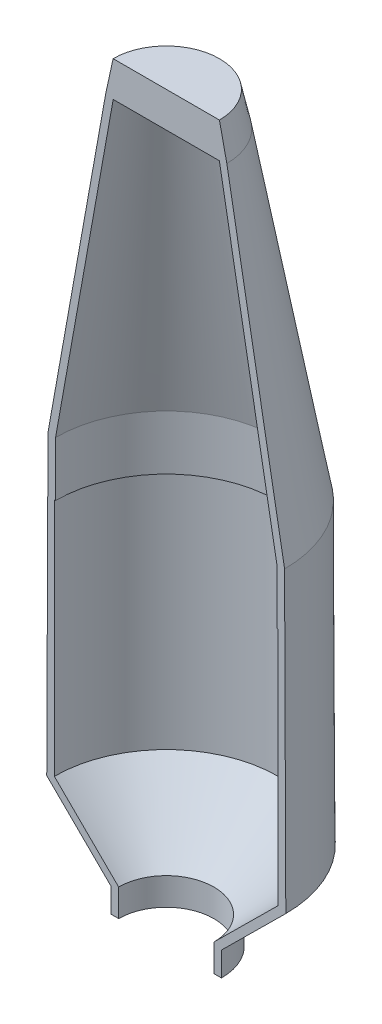
from build123d import *

# Parameters (mm, degrees)
EXTRUDE1_DEPTH = 2540


with BuildPart() as part:
    # Sketch1 → Revolve1 (revolve)
    with BuildSketch(Plane(origin=(0, 0, 0), x_dir=(0, 0, -1), z_dir=(1, 0, 0))):
        with BuildLine():
            Line((889, 5386.324), (1854.2, 0.000254))
            Line((1854.2, 0.000254), (1854.2, -914.399746))
            Line((1854.2, -914.399746), (1875.028, -914.399746))
            Line((1875.028, -914.399746), (1875.028, -4925.059746))
            Line((1875.028, -4925.059746), (797.687, -5991.859746))
            Line((797.687, -5991.859746), (797.687, -6450.585559605))
            Line((797.687, -6450.585559605), (924.687, -6450.585559605))
            Line((924.687, -6450.585559605), (924.687, -6044.830978169))
            Line((924.687, -6044.830978169), (2002.028, -4978.030978169))
            Line((2002.028, -4978.030978169), (1981.2, 11.289201635))
            Line((1981.2, 11.289201635), (1014.008798645, 5408.724898673))
            Line((1014.008798645, 5408.724898673), (797.687, 6403.505182835))
            ThreePointArc((797.687, 6403.505182835), (486.180167613, 6776.837110866), (0, 6783.324))
            Line((0, 6783.324), (0, 5386.324))
            Line((0, 5386.324), (889, 5386.324))
        make_face()
    revolve(axis=Axis((0, 0, 0), (0, 1, 0)))

    # Sketch4 → Extrude1 (cut, symmetric)
    with BuildSketch(Plane(origin=(0, 0, 0), x_dir=(0, 0, -1), z_dir=(1, 0, 0))):
        Polygon((-2694.362822344, 5977.135663923), (-3046.020950611, 5977.135663923), (-3046.020950611, 7002.576510216), (7037.614377191, 7002.576510216), (7037.614377191, 5977.135663923), (0, 5977.135663923), (0, -7682.399338872), (-2694.362822344, -7682.399338872), align=None)
    extrude(amount=EXTRUDE1_DEPTH, both=True, mode=Mode.SUBTRACT)


solid = part.part
